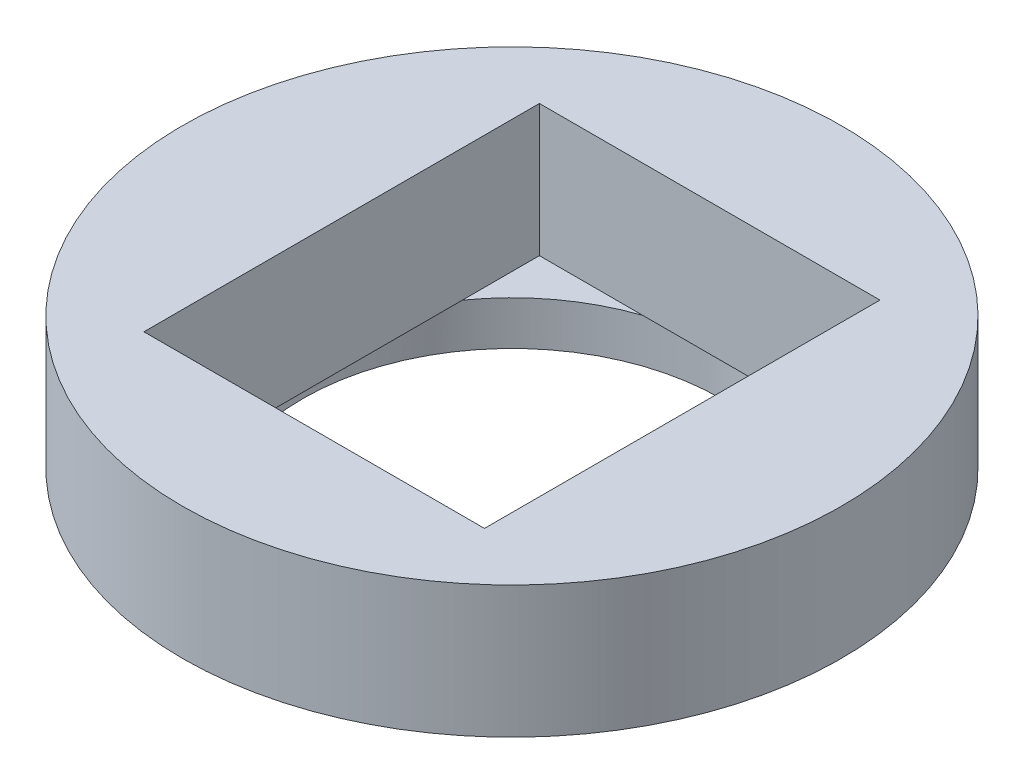
from build123d import *

# Parameters (mm, degrees)
ESQUISSE1_R        = 11.975
ESQUISSE1_R_2      = 9.5
BOSS_EXTRU_1_DEPTH = 2
ESQUISSE3_R        = 15
ESQUISSE3_W        = 15.5
ESQUISSE3_H        = 18
BOSS_EXTRU_5_DEPTH = 2
ESQUISSE8_R        = 15
ESQUISSE8_W        = 15.5
ESQUISSE8_H        = 18
BOSS_EXTRU_6_DEPTH = 4


with BuildPart() as part:
    # Esquisse1 → Boss.-Extru.1 (new body)
    with BuildSketch(Plane(origin=(0, 0, 0), x_dir=(1, 0, 0), z_dir=(0, 1, 0))):
        Circle(ESQUISSE1_R)
        Circle(ESQUISSE1_R_2, mode=Mode.SUBTRACT)
    extrude(amount=BOSS_EXTRU_1_DEPTH)

    # Esquisse3 → Boss.-Extru.5 (add)
    with BuildSketch(Plane(origin=(0, 2, 0), x_dir=(1, 0, 0), z_dir=(0, 1, 0))):
        Circle(ESQUISSE3_R)
        Rectangle(ESQUISSE3_W, ESQUISSE3_H, mode=Mode.SUBTRACT)
    extrude(amount=BOSS_EXTRU_5_DEPTH)

    # Esquisse8 → Boss.-Extru.6 (add)
    with BuildSketch(Plane(origin=(0, 4, 0), x_dir=(1, 0, 0), z_dir=(0, 1, 0))):
        Circle(ESQUISSE8_R)
        Rectangle(ESQUISSE8_W, ESQUISSE8_H, mode=Mode.SUBTRACT)
    extrude(amount=BOSS_EXTRU_6_DEPTH)


solid = part.part
